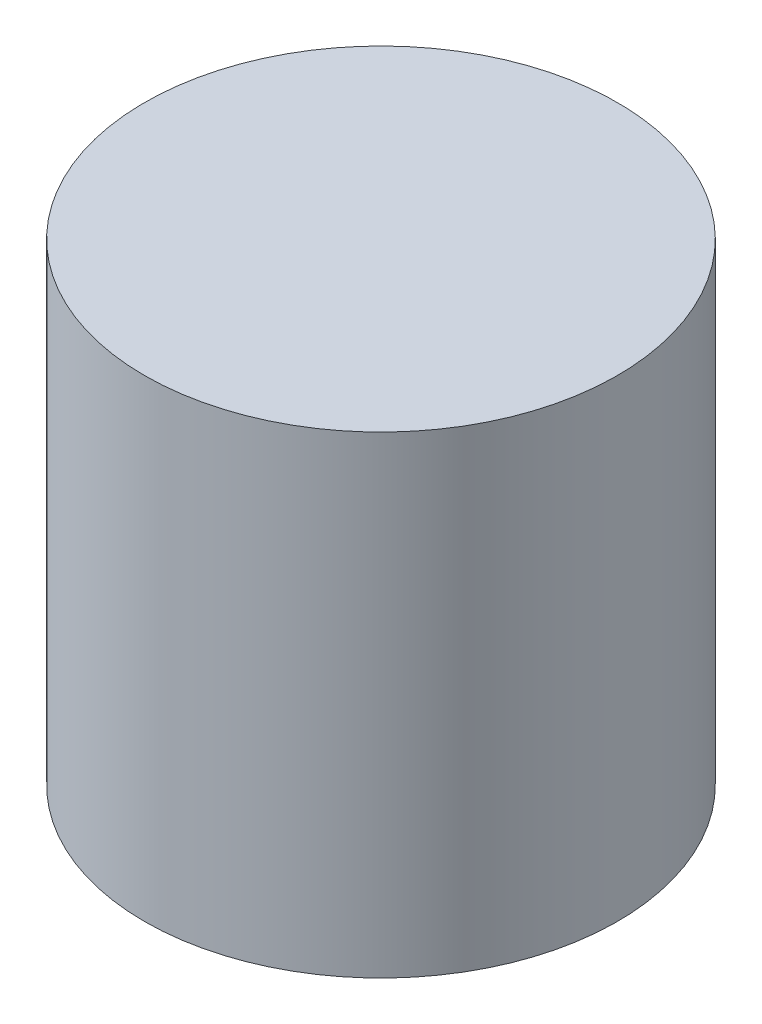
from build123d import *

# Parameters (mm, degrees)
SKETCH1_R           = 10
BOSS_EXTRUDE1_DEPTH = 20
SKETCH2_R           = 3.125
CUT_EXTRUDE1_DEPTH  = 17
SKETCH3_R           = 6
CUT_EXTRUDE2_DEPTH  = 4


with BuildPart() as part:
    # Sketch1 → Boss-Extrude1 (new body)
    with BuildSketch(Plane(origin=(0, 0, 0), x_dir=(1, 0, 0), z_dir=(0, 1, 0))):
        with Locations(Location((0, 0, 0), (0, 0, 270))):  # turned: the seam where the file's is
            Circle(SKETCH1_R)
    extrude(amount=BOSS_EXTRUDE1_DEPTH)

    # Sketch2 → Cut-Extrude1 (cut)
    with BuildSketch(Plane.XZ):
        with Locations(Location((0, 0, 0), (0, 0, 270))):  # turned: the seam where the file's is
            Circle(SKETCH2_R)
    extrude(amount=-CUT_EXTRUDE1_DEPTH, mode=Mode.SUBTRACT)

    # Sketch3 → Cut-Extrude2 (cut)
    with BuildSketch(Plane.XZ):
        with Locations(Location((0, 0, 0), (0, 0, 270))):  # turned: the seam where the file's is
            Circle(SKETCH3_R)
    extrude(amount=-CUT_EXTRUDE2_DEPTH, mode=Mode.SUBTRACT)


solid = part.part
